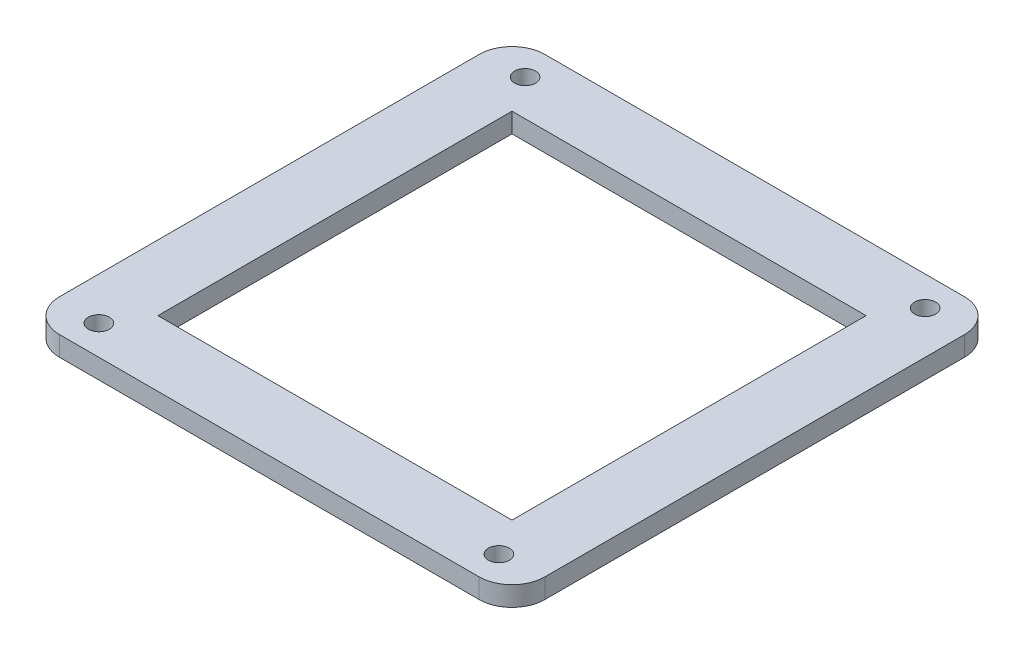
from build123d import *

# Parameters (mm, degrees)
SKETCH1_W                = 74
SKETCH1_H                = 74
SKETCH1_W_2              = 54
SKETCH1_H_2              = 54
BOSS_EXTRUDE1_DEPTH      = 3
M3_CLEARANCE_HOLE1_D     = 3.2
M3_CLEARANCE_HOLE1_DEPTH = 4.5
M3_CLEARANCE_HOLE1_TIP   = 0.96137699
FILLET1_R                = 5


with BuildPart() as part:
    # Sketch1 → Boss-Extrude1 (new body)
    with BuildSketch(Plane(origin=(0, 0, 0), x_dir=(1, 0, 0), z_dir=(0, 1, 0))):
        Rectangle(SKETCH1_W, SKETCH1_H)
        Rectangle(SKETCH1_W_2, SKETCH1_H_2, mode=Mode.SUBTRACT)
    extrude(amount=BOSS_EXTRUDE1_DEPTH)

    # M3 Clearance Hole1
    with Locations(Plane(origin=(-30.5, 3, -32.5), x_dir=(0, 0, 1), z_dir=(0, 1, 0))):
        with Locations((0, 0), (0, 61), (65, 61), (65, 0)):
            Hole(M3_CLEARANCE_HOLE1_D / 2, depth=M3_CLEARANCE_HOLE1_DEPTH)
            with Locations((0, 0, -(M3_CLEARANCE_HOLE1_DEPTH + M3_CLEARANCE_HOLE1_TIP / 2))):  # 118° drill point
                Cone(0, M3_CLEARANCE_HOLE1_D / 2, M3_CLEARANCE_HOLE1_TIP, mode=Mode.SUBTRACT)

    # Fillet1
    fillet1_edges = [part.edges().sort_by_distance(p)[0] for p in [
        (37, 1.5, 37),
        (-37, 1.5, 37),
        (-37, 1.5, -37),
        (37, 1.5, -37),
    ]]
    fillet(fillet1_edges, radius=FILLET1_R)


solid = part.part
